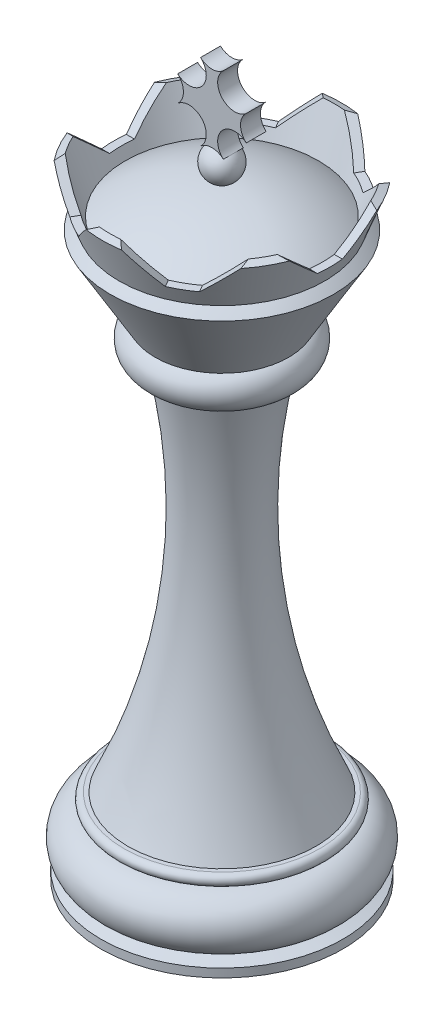
from build123d import *

# Parameters (mm, degrees)
CUT_EXTRUDE2_DEPTH  = 73.444074635
CIRPATTERN1_COUNT   = 6
BOSS_EXTRUDE2_DEPTH = 1.27


with BuildPart() as part:
    # Sketch1 → Revolve1 (revolve)
    with BuildSketch(Plane.XY):
        with BuildLine():
            Line((0, 62.092832387), (0, -9.621899222))
            Line((0, -9.621899222), (15.450410298, -9.621899222))
            Line((15.450410298, -9.621899222), (15.450410298, -8.530075969))
            Line((15.450410298, -8.530075969), (13.893883706, -8.017710004))
            ThreePointArc((13.893883706, -8.017710004), (15.773602868, -4.193417719), (12.478125528, -1.49186544))
            Line((12.478125528, -1.49186544), (12.478125528, -1.42836544))
            ThreePointArc((12.478125528, -1.42836544), (13.215841354, -0.726095063), (12.5015625, 0))
            Line((12.5015625, 0), (11.997414701, 0))
            ThreePointArc((11.997414701, 0), (5.464835652, 23.483515884), (6.82815225, 47.820555045))
            ThreePointArc((6.82815225, 47.820555045), (9.567883495, 49.335061774), (8.523197639, 52.28607675))
            Line((8.523197639, 52.28607675), (14.236628464, 62.092832387))
            Line((14.236628464, 62.092832387), (0, 62.092832387))
        make_face()
        with BuildLine():
            ThreePointArc((12.312836707, 63.599407377), (12.718455434, 63.310302464), (13.117288677, 63.01190634))
            Line((13.117288677, 63.01190634), (15.233285791, 68.544965448))
            Line((15.233285791, 68.544965448), (14.335464413, 68.888317545))
            Line((14.335464413, 68.888317545), (12.312836707, 63.599407377))
        make_face()
    revolve(axis=Axis((0, 0, 0), (0, -1, 0)))

    # Sketch8 → Cut-Extrude2 (cut, through all)
    with BuildSketch(Plane(origin=(0, 0, 0), x_dir=(0, 0, -1), z_dir=(1, 0, 0))):
        Polygon((-1.59226478, 64.974275528), (1.59226478, 64.974275528), (7.116771659, 69.925609864), (-7.116771659, 69.925609864), align=None)
    cut_extrude2 = extrude(amount=CUT_EXTRUDE2_DEPTH, mode=Mode.SUBTRACT)

    # CirPattern1: Cut-Extrude2 ×6 about axis
    cirpattern1_axis = Axis((0, -9.621899222, 0), (0, 1, 0))
    for i in range(1, CIRPATTERN1_COUNT):
        add(cut_extrude2.rotate(cirpattern1_axis, i * 360 / CIRPATTERN1_COUNT), mode=Mode.SUBTRACT)

    # Sketch1_10 → Revolve2 (revolve)
    with BuildSketch(Plane.XY):
        with BuildLine():
            Line((0, 62.092832387), (14.236628464, 62.092832387))
            ThreePointArc((14.236628464, 62.092832387), (7.683132909, 66.044999268), (0.162020231, 67.459492514))
            ThreePointArc((0.162020231, 67.459492514), (2.186429811, 69.722483228), (0, 71.829349573))
            Line((0, 71.829349573), (0, 62.092832387))
        make_face()
    revolve(axis=Axis((0, 67.460101163, 0), (0, 1, 0)))


with BuildPart() as body_2:
    # Sketch1_11 → Boss-Extrude2 (new, symmetric)
    with BuildSketch(Plane.XY):
        with BuildLine():
            ThreePointArc((4.37334596, 77.799122776), (3.643189315, 76.167578222), (4.37334596, 74.536033667))
            ThreePointArc((4.37334596, 74.536033667), (1.284030288, 74.362269473), (1.457785241, 71.272953281))
            ThreePointArc((1.457785241, 71.272953281), (0, 71.829349573), (-1.457785241, 71.272953281))
            ThreePointArc((-1.457785241, 71.272953281), (-1.284030288, 74.362269473), (-4.37334596, 74.536033667))
            ThreePointArc((-4.37334596, 74.536033667), (-3.643189315, 76.167578222), (-4.37334596, 77.799122776))
            ThreePointArc((-4.37334596, 77.799122776), (-1.284030288, 77.97288697), (-1.457785241, 81.062203162))
            ThreePointArc((-1.457785241, 81.062203162), (0, 80.50580687), (1.457785241, 81.062203162))
            ThreePointArc((1.457785241, 81.062203162), (1.284030288, 77.97288697), (4.37334596, 77.799122776))
        make_face()
    extrude(amount=BOSS_EXTRUDE2_DEPTH, both=True)


solid = Compound([part.part, body_2.part])
